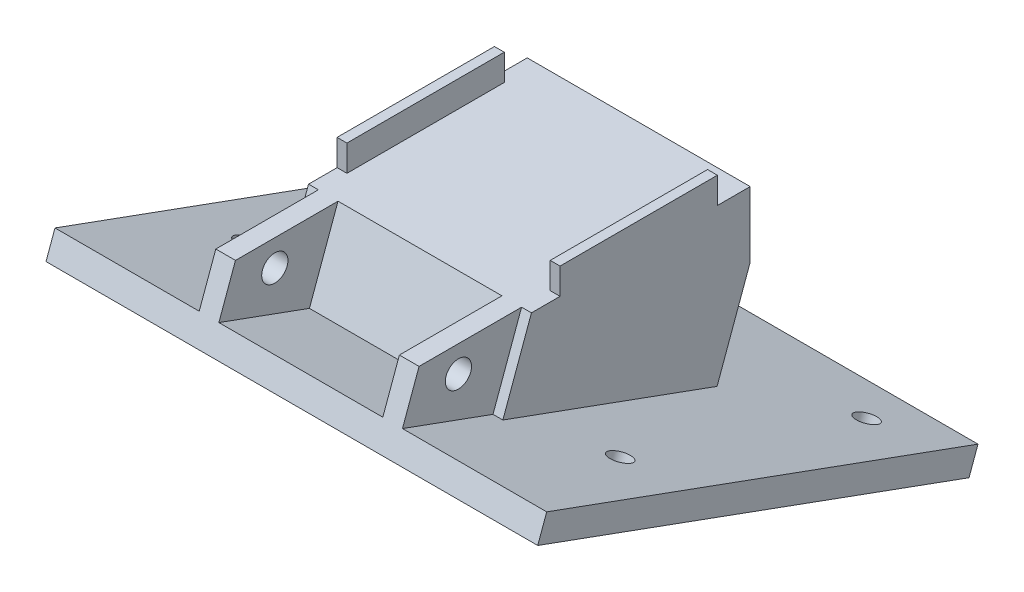
from build123d import *

# Parameters (mm, degrees)
SKETCH_1_W           = 34
SKETCH_1_H           = 49
EXTRUDE_1_DEPTH      = 10
SKETCH_2_W           = 1.5
SKETCH_2_H           = 24
EXTRUDE_2_DEPTH      = 4
SKETCH_3_W           = 1.5
SKETCH_3_H           = 12
SKETCH_3_W_2         = 25
SKETCH_3_H_2         = 13
CUT_EXTRUDE_1_DEPTH  = 10
SKETCH_4_R           = 2
CUT_EXTRUDE_2_DEPTH  = 31
EXTRUDE_3_DEPTH      = 8
CUT_EXTRUDE_4_DEPTH  = 10
EXTRUDE_4_DEPTH      = 3
EXTRUDE_5_DEPTH      = 3
EXTRUDE_6_DEPTH      = 3
EXTRUDE_7_DEPTH      = 34
EXTRUDE_8_DEPTH      = 3
EXTRUDE_9_REACH      = 31.5
CUT_EXTRUDE_10_DEPTH = 1.5
CUT_EXTRUDE_11_DEPTH = 1.5
CUT_EXTRUDE_12_DEPTH = 25
SKETCH_18_W          = 75
SKETCH_18_H          = 70
SKETCH_18_R          = 1.65
EXTRUDE_10_DEPTH     = 2


with BuildPart() as part:
    # Sketch 1 → Extrude 1 (new body)
    with BuildSketch(Plane(origin=(0, 0, 0), x_dir=(1, 0, 0), z_dir=(0, 1, 0))):
        Rectangle(SKETCH_1_W, SKETCH_1_H)
    extrude(amount=EXTRUDE_1_DEPTH)

    # Sketch 2 → Extrude 2 (add)
    with BuildSketch(Plane(origin=(0, 10, 0), x_dir=(1, 0, 0), z_dir=(0, 1, 0))):
        with Locations((-16.25, 7.5)):
            Rectangle(SKETCH_2_W, SKETCH_2_H)
        with Locations((16.25, 7.5)):
            Rectangle(SKETCH_2_W, SKETCH_2_H)
    extrude(amount=EXTRUDE_2_DEPTH)

    # Sketch 3 → Cut-Extrude 1 (cut)
    with BuildSketch(Plane(origin=(0, 10, 0), x_dir=(1, 0, 0), z_dir=(0, 1, 0))):
        with Locations((-16.25, -18.5)):
            Rectangle(SKETCH_3_W, SKETCH_3_H)
        with Locations((16.25, -18.5)):
            Rectangle(SKETCH_3_W, SKETCH_3_H)
        with Locations((0, -18)):
            Rectangle(SKETCH_3_W_2, SKETCH_3_H_2)
    extrude(amount=-CUT_EXTRUDE_1_DEPTH, mode=Mode.SUBTRACT)

    # Sketch 4 → Cut-Extrude 2 (cut)
    with BuildSketch(Plane.ZY.offset(15.5)):
        with Locations((18.5, 6)):
            Circle(SKETCH_4_R)
    extrude(amount=-CUT_EXTRUDE_2_DEPTH, mode=Mode.SUBTRACT)

    # Sketch 5 → Extrude 3 (add)
    with BuildSketch(Plane.XZ):
        Polygon((4, 11.5), (-4, 11.5), (-4, 41.5), (-13, 41.5), (-13, 56.5), (13, 56.5), (13, 41.5), (4, 41.5), align=None)
    extrude(amount=-EXTRUDE_3_DEPTH)

    # Sketch 5_2 → Cut-Extrude 4 (cut)
    with BuildSketch(Plane.XZ):
        Polygon((4, 11.5), (-4, 11.5), (-4, 41.5), (-13, 41.5), (-13, 56.5), (13, 56.5), (13, 41.5), (4, 41.5), align=None)
    extrude(amount=-CUT_EXTRUDE_4_DEPTH, mode=Mode.SUBTRACT)

    # Sketch 7 → Extrude 4 (add)
    with BuildSketch(Plane.ZY.offset(15.5)):
        Polygon((24.5, 10), (27.713938048, 1.169777784), (24.5, 0), align=None)
    extrude(amount=-EXTRUDE_4_DEPTH)

    # Sketch 8 → Extrude 5 (add)
    with BuildSketch(Plane(origin=(15.5, 0, 0), x_dir=(0, 0, -1), z_dir=(1, 0, 0))):
        Polygon((-27.713938048, 1.169777784), (-24.5, 0), (-24.5, 10), align=None)
    extrude(amount=-EXTRUDE_5_DEPTH)

    # Sketch 9 → Extrude 6 (add)
    with BuildSketch(Plane(origin=(15.5, 0, 0), x_dir=(0, 0, -1), z_dir=(1, 0, 0))):
        Polygon((-12.5, 0), (-24.5, 0), (-13.903733341, -3.856725658), align=None)
    extrude(amount=-EXTRUDE_6_DEPTH)

    # Sketch 10 → Extrude 7 (add)
    with BuildSketch(Plane(origin=(17, 0, 0), x_dir=(0, 0, -1), z_dir=(1, 0, 0))):
        Polygon((-12.5, 0), (-13.903733341, -3.856725658), (18.768088856, -15.748296437), (24.5, 0), align=None)
    extrude(amount=-EXTRUDE_7_DEPTH)

    # Sketch 11 → Extrude 8 (add)
    with BuildSketch(Plane.ZY.offset(15.5)):
        Polygon((24.5, 0), (13.903733341, -3.856725658), (12.5, 0), align=None)
    extrude(amount=-EXTRUDE_8_DEPTH)

    # Sketch 12 → Extrude 9 (add, up to next)
    with BuildSketch(Plane(origin=(-12.5, 0, 0), x_dir=(0, 0, -1), z_dir=(1, 0, 0)), mode=Mode.PRIVATE) as extrude_9_sk1:
        Polygon((-12.5, 0), (-11.5, 2.747477419), (-11.5, 0), align=None)
    extrude_9_tool1 = extrude(extrude_9_sk1.sketch, amount=EXTRUDE_9_REACH, mode=Mode.PRIVATE) - part.part
    add(extrude_9_tool1.solids().sort_by_distance((-12.5, 0.915826, 11.833333))[0])

    # Sketch 13 → Cut-Extrude 10 (cut)
    with BuildSketch(Plane(origin=(17, 0, 0), x_dir=(0, 0, -1), z_dir=(1, 0, 0))):
        Polygon((-12.5, 0), (-8.860297657, 10), (-12.5, 10), align=None)
    extrude(amount=-CUT_EXTRUDE_10_DEPTH, mode=Mode.SUBTRACT)

    # Sketch 16 → Cut-Extrude 11 (cut)
    with BuildSketch(Plane.ZY.offset(17)):
        Polygon((12.5, 10), (12.5, 0), (8.860297657, 10), align=None)
    extrude(amount=-CUT_EXTRUDE_11_DEPTH, mode=Mode.SUBTRACT)

    # Sketch 17 → Cut-Extrude 12 (cut)
    with BuildSketch(Plane(origin=(-12.5, 0, 0), x_dir=(0, 0, -1), z_dir=(1, 0, 0))):
        Polygon((-11.5, 2.747477419), (-11.5, 10), (-8.860297657, 10), align=None)
    extrude(amount=CUT_EXTRUDE_12_DEPTH, mode=Mode.SUBTRACT)

    # Sketch 18 → Extrude 10 (add, symmetric)
    with BuildSketch(Plane(origin=(0, -7.874148219, 2.865955572), x_dir=(1, 0, 0), z_dir=(0, -0.939692621, 0.342020143))):
        with Locations((0, -8.557329357)):
            Rectangle(SKETCH_18_W, SKETCH_18_H)
        with Locations((28.5, 4.942670643)):
            Circle(SKETCH_18_R, mode=Mode.SUBTRACT)
        with Locations((28.5, -35.057329357)):
            Circle(SKETCH_18_R, mode=Mode.SUBTRACT)
        with Locations((-28.5, 4.942670643)):
            Circle(SKETCH_18_R, mode=Mode.SUBTRACT)
        with Locations((-28.5, -35.057329357)):
            Circle(SKETCH_18_R, mode=Mode.SUBTRACT)
    extrude(amount=EXTRUDE_10_DEPTH, both=True)


solid = part.part
